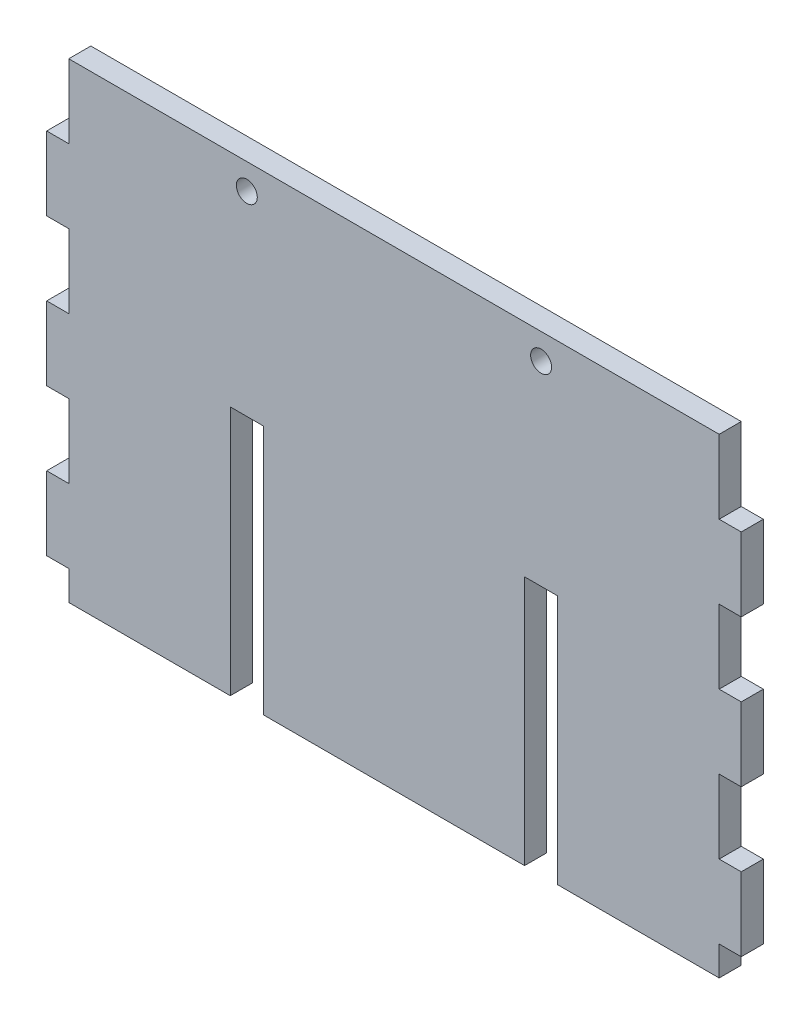
from build123d import *

# Parameters (mm, degrees)
SKETCH1_W           = 94.4
SKETCH1_H           = 64
BOSS_EXTRUDE1_DEPTH = 3
SKETCH2_W           = 3
SKETCH2_H           = 10
CUT_EXTRUDE1_DEPTH  = 3
SKETCH3_W           = 4.5
SKETCH3_H           = 34
CUT_EXTRUDE2_DEPTH  = 10
SKETCH4_R           = 1.4224
CUT_EXTRUDE3_DEPTH  = 6


with BuildPart() as part:
    # Sketch1 → Boss-Extrude1 (new body)
    with BuildSketch(Plane.XY):
        Rectangle(SKETCH1_W, SKETCH1_H)
    extrude(amount=BOSS_EXTRUDE1_DEPTH)

    # Sketch2 → Cut-Extrude1 (cut)
    with BuildSketch(Plane(origin=(0, 0, 0), x_dir=(-1, 0, 0), z_dir=(0, 0, -1))):
        with Locations((-45.7, 7)):
            Rectangle(SKETCH2_W, SKETCH2_H)
        with Locations((-45.7, 27)):
            Rectangle(SKETCH2_W, SKETCH2_H)
        with Locations((-45.7, -13)):
            Rectangle(SKETCH2_W, SKETCH2_H)
        with Locations((-45.7, -33)):
            Rectangle(SKETCH2_W, SKETCH2_H)
        with Locations((45.7, -33)):
            Rectangle(SKETCH2_W, SKETCH2_H)
        with Locations((45.7, -13)):
            Rectangle(SKETCH2_W, SKETCH2_H)
        with Locations((45.7, 7)):
            Rectangle(SKETCH2_W, SKETCH2_H)
        with Locations((45.7, 27)):
            Rectangle(SKETCH2_W, SKETCH2_H)
    extrude(amount=-CUT_EXTRUDE1_DEPTH, mode=Mode.SUBTRACT)

    # Sketch3 → Cut-Extrude2 (cut)
    with BuildSketch(Plane(origin=(0, 0, 0), x_dir=(-1, 0, 0), z_dir=(0, 0, -1))):
        with Locations((-20, -15)):
            Rectangle(SKETCH3_W, SKETCH3_H)
        with Locations((20, -15)):
            Rectangle(SKETCH3_W, SKETCH3_H)
    extrude(amount=-CUT_EXTRUDE2_DEPTH, mode=Mode.SUBTRACT)

    # Sketch4 → Cut-Extrude3 (cut)
    with BuildSketch(Plane(origin=(0, 0, 0), x_dir=(-1, 0, 0), z_dir=(0, 0, -1))):
        with Locations((-20, 28.5)):
            Circle(SKETCH4_R)
        with Locations((20, 28.5)):
            Circle(SKETCH4_R)
    extrude(amount=-CUT_EXTRUDE3_DEPTH, mode=Mode.SUBTRACT)


solid = part.part
